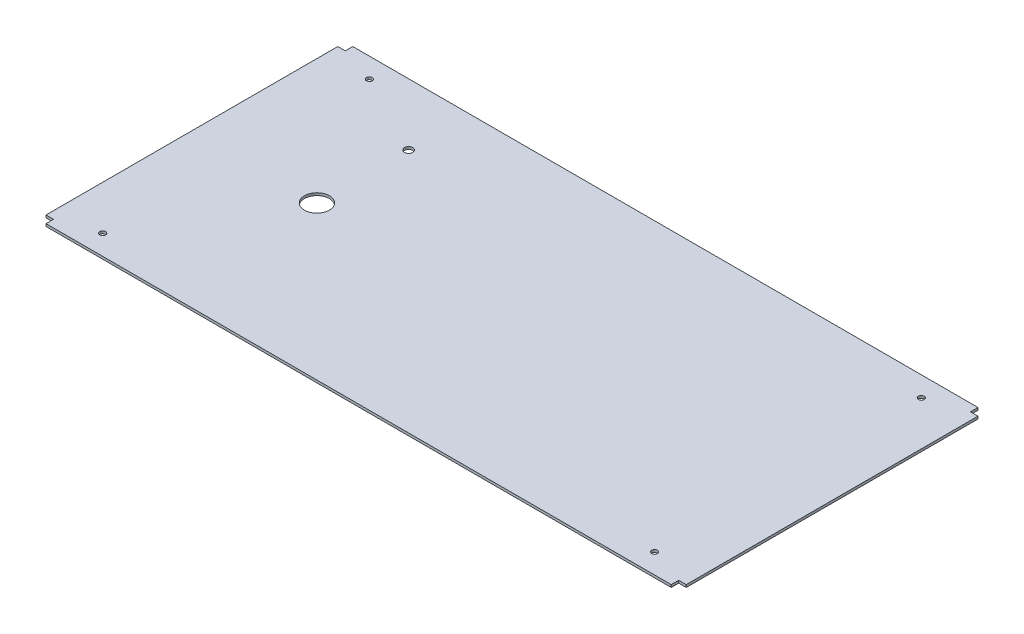
from build123d import *

# Parameters (mm, degrees)
SKETCH2_R           = 3.5
BOSS_EXTRUDE1_DEPTH = 3
SKETCH3_R           = 15
CUT_EXTRUDE1_DEPTH  = 4
SKETCH4_R           = 5
CUT_EXTRUDE2_DEPTH  = 4


with BuildPart() as part:
    # Sketch2 → Boss-Extrude1 (new body)
    with BuildSketch(Plane(origin=(0, 0, 0), x_dir=(1, 0, 0), z_dir=(0, 1, 0))):
        Polygon((-375, 184), (375, 184), (375, 175), (384, 175), (384, -175), (375, -175), (375, -184), (-375, -184), (-375, -175), (-384, -175), (-384, 175), (-375, 175), align=None)
        with Locations((-331.06, 160)):
            Circle(SKETCH2_R, mode=Mode.SUBTRACT)
        with Locations((-331.06, -160)):
            Circle(SKETCH2_R, mode=Mode.SUBTRACT)
        with Locations((331.06, 160)):
            Circle(SKETCH2_R, mode=Mode.SUBTRACT)
        with Locations((331.06, -160)):
            Circle(SKETCH2_R, mode=Mode.SUBTRACT)
    extrude(amount=BOSS_EXTRUDE1_DEPTH)

    # Sketch3 → Cut-Extrude1 (cut, through all)
    with BuildSketch(Plane(origin=(0, 3, 0), x_dir=(1, 0, 0), z_dir=(0, 1, 0))):
        with Locations((-234, 0)):
            Circle(SKETCH3_R)
    extrude(amount=-CUT_EXTRUDE1_DEPTH, mode=Mode.SUBTRACT)

    # Sketch4 → Cut-Extrude2 (cut, through all)
    with BuildSketch(Plane(origin=(0, 3, 0), x_dir=(1, 0, 0), z_dir=(0, 1, 0))):
        with Locations((-234, 110)):
            Circle(SKETCH4_R)
    extrude(amount=-CUT_EXTRUDE2_DEPTH, mode=Mode.SUBTRACT)


solid = part.part
